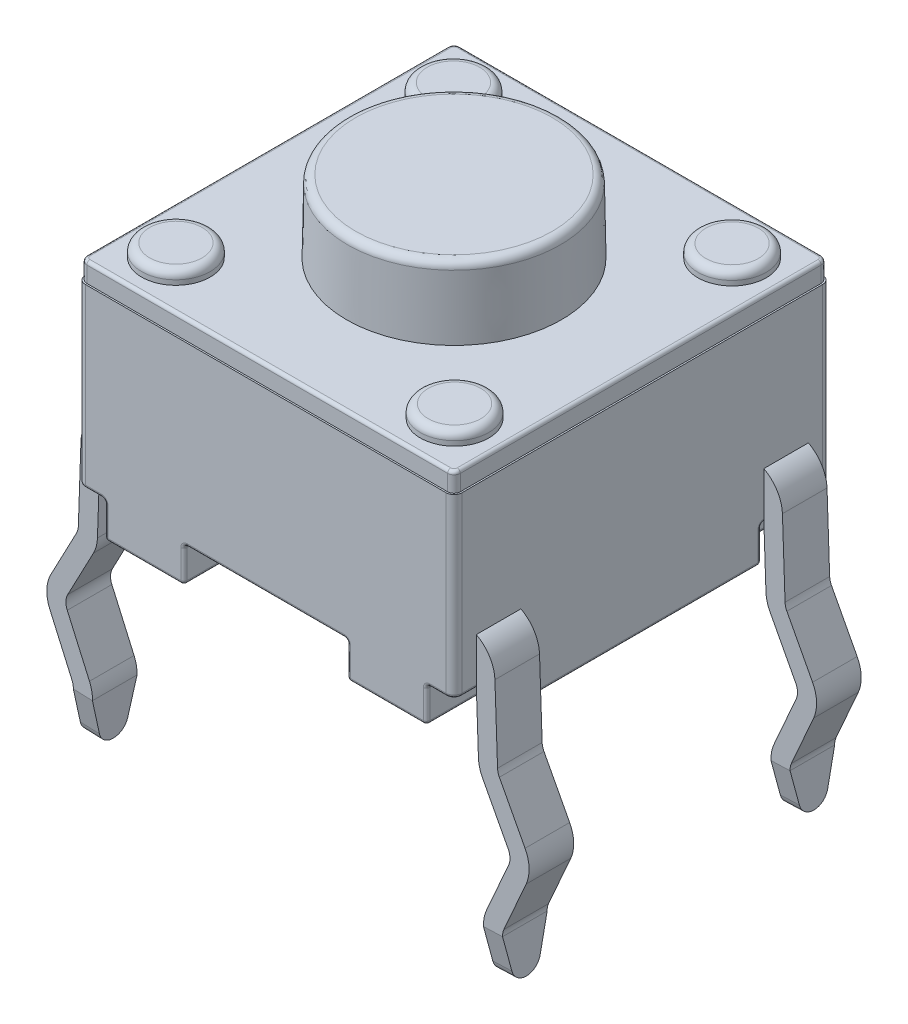
from build123d import *

# Parameters (mm, degrees)
BOSS_EXTRUDE1_START  = 0.5588
SKETCH1_W            = 6.0071
SKETCH1_H            = 6.0071
BOSS_EXTRUDE1_DEPTH  = 2.8194
FILLET1_R            = 0.127
BOSS_EXTRUDE2_DEPTH  = 0.3048
BOSS_EXTRUDE3_REACH  = 7.622
SKETCH4_R            = 0.5461
BOSS_EXTRUDE4_DEPTH  = 0.2032
SKETCH5_R            = 1.7145
BOSS_EXTRUDE5_DEPTH  = 1.15
BOSS_EXTRUDE5_TAPER  = 1
FILLET2_R            = 0.127
FILLET3_R            = 0.0508
EXTRUDE_THIN1_START  = -0.3556
EXTRUDE_THIN1_DEPTH  = 0.7112
CUT_EXTRUDE1_DEPTH   = 0.7112
MIRROR3_START        = -0.3556
MIRROR3_COPY_1_DEPTH = 0.7112
MIRROR3_COPY_2_DEPTH = 0.7112


with BuildPart() as part:
    # Sketch1 → Boss-Extrude1 (new body)
    with BuildSketch(Plane(origin=(0, 0, 0), x_dir=(1, 0, 0), z_dir=(0, 1, 0)).offset(BOSS_EXTRUDE1_START)):
        Rectangle(SKETCH1_W, SKETCH1_H)
    extrude(amount=BOSS_EXTRUDE1_DEPTH)

    # Fillet1
    fillet1_edges = [part.edges().sort_by_distance(p)[0] for p in [
        (3.00355, 1.9685, 3.00355),
        (-3.00355, 1.9685, 3.00355),
        (-3.00355, 1.9685, -3.00355),
        (3.00355, 1.9685, -3.00355),
    ]]
    fillet(fillet1_edges, radius=FILLET1_R)

    # Sketch2 → Boss-Extrude2 (add)
    with BuildSketch(Plane(origin=(0, 3.3782, 0), x_dir=(-1, 0, 0), z_dir=(0, -1, 0))):
        with BuildLine():
            Line((2.97815, -2.87655), (2.97815, 2.87655))
            ThreePointArc((2.97815, 2.87655), (2.948392049, 2.948392049), (2.87655, 2.97815))
            Line((2.87655, 2.97815), (-2.87655, 2.97815))
            ThreePointArc((-2.87655, 2.97815), (-2.948392049, 2.948392049), (-2.97815, 2.87655))
            Line((-2.97815, 2.87655), (-2.97815, -2.87655))
            ThreePointArc((-2.97815, -2.87655), (-2.948392049, -2.948392049), (-2.87655, -2.97815))
            Line((-2.87655, -2.97815), (2.87655, -2.97815))
            ThreePointArc((2.87655, -2.97815), (2.948392049, -2.948392049), (2.97815, -2.87655))
        make_face()
    extrude(amount=-BOSS_EXTRUDE2_DEPTH)

    # Sketch3 → Boss-Extrude3 (add, up to next)
    with BuildSketch(Plane(origin=(0, 0, 0), x_dir=(1, 0, 0), z_dir=(0, 1, 0)), mode=Mode.PRIVATE) as boss_extrude3_sk1:
        Polygon((-2.566197678, -3.00355), (-2.566197678, -1.89483443), (-3.00355, -1.89483443), (-3.00355, 1.89483443), (-2.566197678, 1.89483443), (-2.566197678, 3.00355), (-1.30175, 3.00355), (-1.30175, 0.560941661), (-2.441300776, 0.560941661), (-2.441300776, -0.560941661), (-1.30175, -0.560941661), (-1.30175, -3.00355), align=None)
    boss_extrude3_tool1 = extrude(boss_extrude3_sk1.sketch, amount=BOSS_EXTRUDE3_REACH, mode=Mode.PRIVATE) - part.part
    # Sketch3 → Boss-Extrude3 (add, up to next)
    with BuildSketch(Plane(origin=(0, 0, 0), x_dir=(1, 0, 0), z_dir=(0, 1, 0)), mode=Mode.PRIVATE) as boss_extrude3_sk2:
        Polygon((2.566197678, 3.00355), (2.566197678, 1.89483443), (3.00355, 1.89483443), (3.00355, -1.89483443), (2.566197678, -1.89483443), (2.566197678, -3.00355), (1.30175, -3.00355), (1.30175, -0.560941661), (2.441300776, -0.560941661), (2.441300776, 0.560941661), (1.30175, 0.560941661), (1.30175, 3.00355), align=None)
    boss_extrude3_tool2 = extrude(boss_extrude3_sk2.sketch, amount=BOSS_EXTRUDE3_REACH, mode=Mode.PRIVATE) - part.part
    add(boss_extrude3_tool1.solids().sort_by_distance((-2.503763, 0, 2.449192))[0])
    add(boss_extrude3_tool2.solids().sort_by_distance((2.503763, 0, -2.449192))[0])

    # Sketch4 → Boss-Extrude4 (add)
    with BuildSketch(Plane(origin=(0, 3.683, 0), x_dir=(1, 0, 0), z_dir=(0, 1, 0))):
        with Locations(Location((2.221694311, 2.212885437, 0), (0, 0, 90))):
            Circle(SKETCH4_R)
        with Locations(Location((-2.221694311, 2.212885437, 0), (0, 0, 90))):
            Circle(SKETCH4_R)
        with Locations(Location((-2.221694311, -2.212885437, 0), (0, 0, 90))):
            Circle(SKETCH4_R)
        with Locations(Location((2.221694311, -2.212885437, 0), (0, 0, 90))):
            Circle(SKETCH4_R)
    extrude(amount=BOSS_EXTRUDE4_DEPTH)

    # Sketch5 → Boss-Extrude5 (add)
    with BuildSketch(Plane(origin=(0, 3.683, 0), x_dir=(1, 0, 0), z_dir=(0, 1, 0))):
        Circle(SKETCH5_R)
    extrude(amount=BOSS_EXTRUDE5_DEPTH, taper=BOSS_EXTRUDE5_TAPER)

    # Fillet2
    fillet2_edges = [part.edges().sort_by_distance(p)[0] for p in [
        (2.221694311, 3.8862, -1.666785437),
        (-2.221694311, 3.8862, -1.666785437),
        (-2.221694311, 3.8862, 2.758985437),
        (2.221694311, 3.8862, 2.758985437),
        (-1.694426675, 4.833, 0),
    ]]
    fillet(fillet2_edges, radius=FILLET2_R)

    # Fillet3
    fillet3_edges = [part.edges().sort_by_distance(p)[0] for p in [
        (1.30175, 0.5588, -1.782245831),
        (1.30175, 0.2794, -3.00355),
        (1.30175, 0, -1.782245831),
        (1.871525388, 0.5588, -0.560941661),
        (1.30175, 0.2794, -0.560941661),
        (1.871525388, 0, -0.560941661),
        (2.441300776, 0.5588, 0),
        (2.441300776, 0.2794, -0.560941661),
        (2.441300776, 0, 0),
        (1.871525388, 0.5588, 0.560941661),
        (2.441300776, 0.2794, 0.560941661),
        (1.871525388, 0, 0.560941661),
        (1.30175, 0.5588, 1.782245831),
        (1.30175, 0.2794, 0.560941661),
        (1.30175, 0, 1.782245831),
        (1.30175, 0.2794, 3.00355),
        (1.933973839, 0, 3.00355),
        (2.566197678, 0.5588, 2.449192215),
        (2.566197678, 0.2794, 3.00355),
        (2.566197678, 0, 2.449192215),
        (2.784873839, 0.5588, 1.89483443),
        (2.566197678, 0.2794, 1.89483443),
        (2.784873839, 0, 1.89483443),
        (3.00355, 0.2794, 1.89483443),
        (3.00355, 0, 0),
        (2.784873839, 0.5588, -1.89483443),
        (3.00355, 0.2794, -1.89483443),
        (2.784873839, 0, -1.89483443),
        (2.566197678, 0.2794, -3.00355),
        (1.933973839, 0, -3.00355),
        (2.566197678, 0.5588, -2.449192215),
        (2.566197678, 0.2794, -1.89483443),
        (2.566197678, 0, -2.449192215),
        (-2.721373839, 0.5588, 3.00355),
        (3.00355, 0.5588, 2.385692215),
        (-3.00355, 0.5588, -2.385692215),
        (2.721373839, 0.5588, -3.00355),
        (2.966352561, 0.5588, 2.966352561),
        (2.966352561, 0.5588, -2.966352561),
        (-2.966352561, 0.5588, -2.966352561),
        (-2.966352561, 0.5588, 2.966352561),
        (-2.948392049, 3.683, 2.948392049),
        (0, 3.683, 2.97815),
        (2.948392049, 3.683, 2.948392049),
        (2.97815, 3.683, 0),
        (2.948392049, 3.683, -2.948392049),
        (0, 3.683, -2.97815),
        (-2.948392049, 3.683, -2.948392049),
        (-2.97815, 3.683, 0),
        (0, 0.5588, 3.00355),
        (-3.00355, 0.5588, 2.385692215),
        (-2.721373839, 0.5588, -3.00355),
        (-1.30175, 0.5588, 1.782245831),
        (-1.30175, 0.2794, 3.00355),
        (-1.30175, 0, 1.782245831),
        (-1.871525388, 0.5588, 0.560941661),
        (-1.30175, 0.2794, 0.560941661),
        (-1.871525388, 0, 0.560941661),
        (-2.441300776, 0.5588, 0),
        (-2.441300776, 0.2794, 0.560941661),
        (-2.441300776, 0, 0),
        (-1.871525388, 0.5588, -0.560941661),
        (-2.441300776, 0.2794, -0.560941661),
        (-1.871525388, 0, -0.560941661),
        (-1.30175, 0.5588, -1.782245831),
        (-1.30175, 0.2794, -0.560941661),
        (-1.30175, 0, -1.782245831),
        (-1.30175, 0.2794, -3.00355),
        (-1.933973839, 0, -3.00355),
        (-2.566197678, 0.5588, -2.449192215),
        (-2.566197678, 0.2794, -3.00355),
        (-2.566197678, 0, -2.449192215),
        (-2.784873839, 0.5588, -1.89483443),
        (-2.566197678, 0.2794, -1.89483443),
        (-2.784873839, 0, -1.89483443),
        (-3.00355, 0.2794, -1.89483443),
        (-3.00355, 0, 0),
        (-2.784873839, 0.5588, 1.89483443),
        (-3.00355, 0.2794, 1.89483443),
        (-2.784873839, 0, 1.89483443),
        (-2.566197678, 0.2794, 3.00355),
        (-1.933973839, 0, 3.00355),
        (-2.566197678, 0.5588, 2.449192215),
        (-2.566197678, 0.2794, 1.89483443),
        (-2.566197678, 0, 2.449192215),
        (0, 0.5588, -3.00355),
        (3.00355, 0.5588, -2.385692215),
        (2.721373839, 0.5588, 3.00355),
    ]]
    fillet(fillet3_edges, radius=FILLET3_R)

    # Sketch6 → Extrude-Thin1 (add)
    with BuildSketch(Plane.XY.offset(3.00355).offset(EXTRUDE_THIN1_START)):
        with BuildLine():
            Line((-2.526489479, 1.064092226), (-2.74199854, 1.064092226))
            ThreePointArc((-2.74199854, 1.064092226), (-2.918441767, 0.992804535), (-2.995843811, 0.818956698))
            Line((-2.995843811, 0.818956698), (-3.03780929, -0.382777412))
            ThreePointArc((-3.03780929, -0.382777412), (-3.056264298, -0.506985303), (-3.10198813, -0.623936226))
            Line((-3.10198813, -0.623936226), (-3.511410555, -1.400308198))
            ThreePointArc((-3.511410555, -1.400308198), (-3.540582755, -1.509925841), (-3.519128157, -1.62131141))
            Line((-3.519128157, -1.62131141), (-3.164860036, -2.424352043))
            ThreePointArc((-3.164860036, -2.424352043), (-3.127405669, -2.544207613), (-3.117659921, -2.669400296))
            Line((-3.117659921, -2.669400296), (-3.142411752, -3.3782))
            Line((-3.142411752, -3.3782), (-3.447026076, -3.367562633))
            Line((-3.447026076, -3.367562633), (-3.422274245, -2.658762929))
            ThreePointArc((-3.422274245, -2.658762929), (-3.42670413, -2.601857165), (-3.443728843, -2.54737736))
            Line((-3.443728843, -2.54737736), (-3.797996964, -1.744336727))
            ThreePointArc((-3.797996964, -1.744336727), (-3.845197079, -1.499288474), (-3.781018239, -1.25812966))
            Line((-3.781018239, -1.25812966), (-3.371595814, -0.481757688))
            ThreePointArc((-3.371595814, -0.481757688), (-3.350812254, -0.428598178), (-3.342423614, -0.372140046))
            Line((-3.342423614, -0.372140046), (-3.300458135, 0.829594065))
            ThreePointArc((-3.300458135, 0.829594065), (-3.130173638, 1.212059307), (-2.74199854, 1.368892226))
            Line((-2.74199854, 1.368892226), (-2.526489479, 1.368892226))
            Line((-2.526489479, 1.368892226), (-2.526489479, 1.064092226))
        make_face()
    extrude_thin1 = extrude(amount=-EXTRUDE_THIN1_DEPTH)

    # Sketch9 → Cut-Extrude1 (cut)
    with BuildSketch(Plane(origin=(-3.325373038, 0.116124585, 0), x_dir=(0, 0, 1), z_dir=(-0.9993908270190957, 0.03489949670250484, 0))):
        with BuildLine():
            Line((2.64795, -3.48581068), (2.64795, -2.776578932))
            Line((2.64795, -2.776578932), (2.517535772, -3.30911696))
            ThreePointArc((2.517535772, -3.30911696), (2.435466476, -3.436364343), (2.29235, -3.48581068))
            Line((2.29235, -3.48581068), (2.64795, -3.48581068))
        make_face()
        with BuildLine():
            Line((1.93675, -3.48581068), (2.29235, -3.48581068))
            ThreePointArc((2.29235, -3.48581068), (2.149233524, -3.436364343), (2.067164228, -3.30911696))
            Line((2.067164228, -3.30911696), (1.93675, -2.776578932))
            Line((1.93675, -2.776578932), (1.93675, -3.48581068))
        make_face()
    cut_extrude1 = extrude(amount=-CUT_EXTRUDE1_DEPTH, mode=Mode.SUBTRACT)

    # Mirror1: Extrude-Thin1, Cut-Extrude1 across plane
    add(extrude_thin1.mirror(Plane.XY))
    add(cut_extrude1.mirror(Plane.XY), mode=Mode.SUBTRACT)

    # Mirror3: Extrude-Thin1, Cut-Extrude1 across plane
    add(extrude_thin1.mirror(Plane(origin=(0, 0, 0), x_dir=(0, 0, 1), z_dir=(1, 0, 0))))
    add(cut_extrude1.mirror(Plane(origin=(0, 0, 0), x_dir=(0, 0, 1), z_dir=(1, 0, 0))), mode=Mode.SUBTRACT)

    # Mirror3 copy 1 sketch → Mirror3 copy 1 (add)
    with BuildSketch(Plane(origin=(0, 0, -3.00355), x_dir=(-1, 0, 0), z_dir=(0, 0, -1)).offset(MIRROR3_START)):
        with BuildLine():
            Line((-2.526489479, 1.064092226), (-2.74199854, 1.064092226))
            ThreePointArc((-2.74199854, 1.064092226), (-2.918441767, 0.992804535), (-2.995843811, 0.818956698))
            Line((-2.995843811, 0.818956698), (-3.03780929, -0.382777412))
            ThreePointArc((-3.03780929, -0.382777412), (-3.056264298, -0.506985303), (-3.10198813, -0.623936226))
            Line((-3.10198813, -0.623936226), (-3.511410555, -1.400308198))
            ThreePointArc((-3.511410555, -1.400308198), (-3.540582755, -1.509925841), (-3.519128157, -1.62131141))
            Line((-3.519128157, -1.62131141), (-3.164860036, -2.424352043))
            ThreePointArc((-3.164860036, -2.424352043), (-3.127405669, -2.544207613), (-3.117659921, -2.669400296))
            Line((-3.117659921, -2.669400296), (-3.142411752, -3.3782))
            Line((-3.142411752, -3.3782), (-3.447026076, -3.367562633))
            Line((-3.447026076, -3.367562633), (-3.422274245, -2.658762929))
            ThreePointArc((-3.422274245, -2.658762929), (-3.42670413, -2.601857165), (-3.443728843, -2.54737736))
            Line((-3.443728843, -2.54737736), (-3.797996964, -1.744336727))
            ThreePointArc((-3.797996964, -1.744336727), (-3.845197079, -1.499288474), (-3.781018239, -1.25812966))
            Line((-3.781018239, -1.25812966), (-3.371595814, -0.481757688))
            ThreePointArc((-3.371595814, -0.481757688), (-3.350812254, -0.428598178), (-3.342423614, -0.372140046))
            Line((-3.342423614, -0.372140046), (-3.300458135, 0.829594065))
            ThreePointArc((-3.300458135, 0.829594065), (-3.130173638, 1.212059307), (-2.74199854, 1.368892226))
            Line((-2.74199854, 1.368892226), (-2.526489479, 1.368892226))
            Line((-2.526489479, 1.368892226), (-2.526489479, 1.064092226))
        make_face()
    extrude(amount=-MIRROR3_COPY_1_DEPTH)

    # Mirror3 copy 2 sketch → Mirror3 copy 2 (cut)
    with BuildSketch(Plane(origin=(3.325373038, 0.116124585, 0), x_dir=(0, 0, -1), z_dir=(0.9993908270190957, 0.03489949670250484, 0))):
        with BuildLine():
            Line((2.64795, -3.48581068), (2.64795, -2.776578932))
            Line((2.64795, -2.776578932), (2.517535772, -3.30911696))
            ThreePointArc((2.517535772, -3.30911696), (2.435466476, -3.436364343), (2.29235, -3.48581068))
            Line((2.29235, -3.48581068), (2.64795, -3.48581068))
        make_face()
        with BuildLine():
            Line((1.93675, -3.48581068), (2.29235, -3.48581068))
            ThreePointArc((2.29235, -3.48581068), (2.149233524, -3.436364343), (2.067164228, -3.30911696))
            Line((2.067164228, -3.30911696), (1.93675, -2.776578932))
            Line((1.93675, -2.776578932), (1.93675, -3.48581068))
        make_face()
    extrude(amount=-MIRROR3_COPY_2_DEPTH, mode=Mode.SUBTRACT)


solid = part.part
